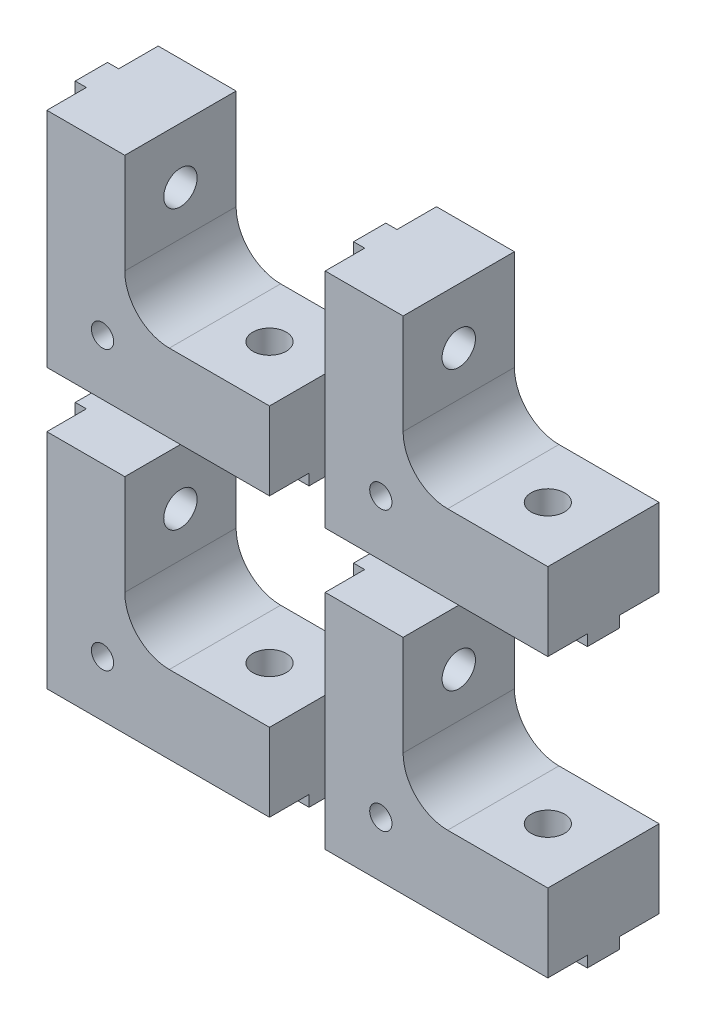
from build123d import *

# Parameters (mm, degrees)
MAIN_DEPTH                         = 10
ESQUISSE4_W                        = 2.9
ESQUISSE4_H                        = 20
MAKERBEAMFIXVERTICAL_DEPTH         = 1
ESQUISSE2_R                        = 1.5
MAKERBEAMVERTICALHOLE_DEPTH        = 2
MAKERBEAMVERTICALHOLE_DEPTH_BACK   = 21
ESQUISSE5_W                        = 20
ESQUISSE5_H                        = 2.9
MAKERBEAMFIXHORIZONTAL_DEPTH       = 1
ESQUISSE3_R                        = 1.5
MAKERBEAMHORIZONTALHOLE_DEPTH      = 2
MAKERBEAMHORIZONTALHOLE_DEPTH_BACK = 21
SKETCH1_R                          = 1
CUT_EXTRUDE1_DEPTH                 = 11
LPATTERN1_COUNT                    = 2
LPATTERN1_PITCH                    = 25
LPATTERN1_2_COUNT                  = 2
LPATTERN1_2_PITCH                  = 25


with BuildPart() as part:
    # Esquisse1 → Main (new body)
    with BuildSketch(Plane.XY):
        with BuildLine():
            Line((0, 0), (20, 0))
            Line((20, 0), (20, 7))
            Line((20, 7), (11, 7))
            ThreePointArc((11, 7), (8.171572875, 8.171572875), (7, 11))
            Line((7, 11), (7, 20))
            Line((7, 20), (0, 20))
            Line((0, 20), (0, 0))
        make_face()
    extrude(amount=MAIN_DEPTH)

    # Esquisse4 → MakerBeamFixVertical (add)
    with BuildSketch(Plane.ZY):
        with Locations((5, 10)):
            Rectangle(ESQUISSE4_W, ESQUISSE4_H)
    extrude(amount=MAKERBEAMFIXVERTICAL_DEPTH)

    # Esquisse2 → MakerBeamVerticalHole (cut, two sides)
    with BuildSketch(Plane.ZY) as makerbeamverticalhole_sk:
        with Locations((5, 15)):
            Circle(ESQUISSE2_R)
    extrude(amount=MAKERBEAMVERTICALHOLE_DEPTH, mode=Mode.SUBTRACT)
    extrude(makerbeamverticalhole_sk.sketch, amount=-MAKERBEAMVERTICALHOLE_DEPTH_BACK, mode=Mode.SUBTRACT)

    # Esquisse5 → MakerBeamFixHorizontal (add)
    with BuildSketch(Plane(origin=(0, 0, 0), x_dir=(-1, 0, 0), z_dir=(0, -1, 0))):
        with Locations((-10, -5)):
            Rectangle(ESQUISSE5_W, ESQUISSE5_H)
    extrude(amount=MAKERBEAMFIXHORIZONTAL_DEPTH)

    # Esquisse3 → MakerBeamHorizontalHole (cut, two sides)
    with BuildSketch(Plane.XZ) as makerbeamhorizontalhole_sk:
        with Locations((15, 5)):
            Circle(ESQUISSE3_R)
    extrude(amount=MAKERBEAMHORIZONTALHOLE_DEPTH, mode=Mode.SUBTRACT)
    extrude(makerbeamhorizontalhole_sk.sketch, amount=-MAKERBEAMHORIZONTALHOLE_DEPTH_BACK, mode=Mode.SUBTRACT)

    # Sketch1 → Cut-Extrude1 (cut, through all)
    with BuildSketch(Plane.XY.offset(10)):
        with Locations((5, 5)):
            Circle(SKETCH1_R)
    extrude(amount=-CUT_EXTRUDE1_DEPTH, mode=Mode.SUBTRACT)


with BuildPart() as lpattern1_1:
    # LPattern1: pattern copy
    add(part.part.moved(Location(Vector(0, 1, 0) * (1 * LPATTERN1_PITCH))))


with BuildPart() as lpattern1_2_1:
    # LPattern1 2: pattern copy
    add(part.part.moved(Location(Vector(1, 0, 0) * (1 * LPATTERN1_2_PITCH))))


with BuildPart() as lpattern1_2_2:
    # LPattern1 2: pattern copy
    add(lpattern1_1.part.moved(Location(Vector(1, 0, 0) * (1 * LPATTERN1_2_PITCH))))


solid = Compound([part.part, lpattern1_1.part, lpattern1_2_1.part, lpattern1_2_2.part])
